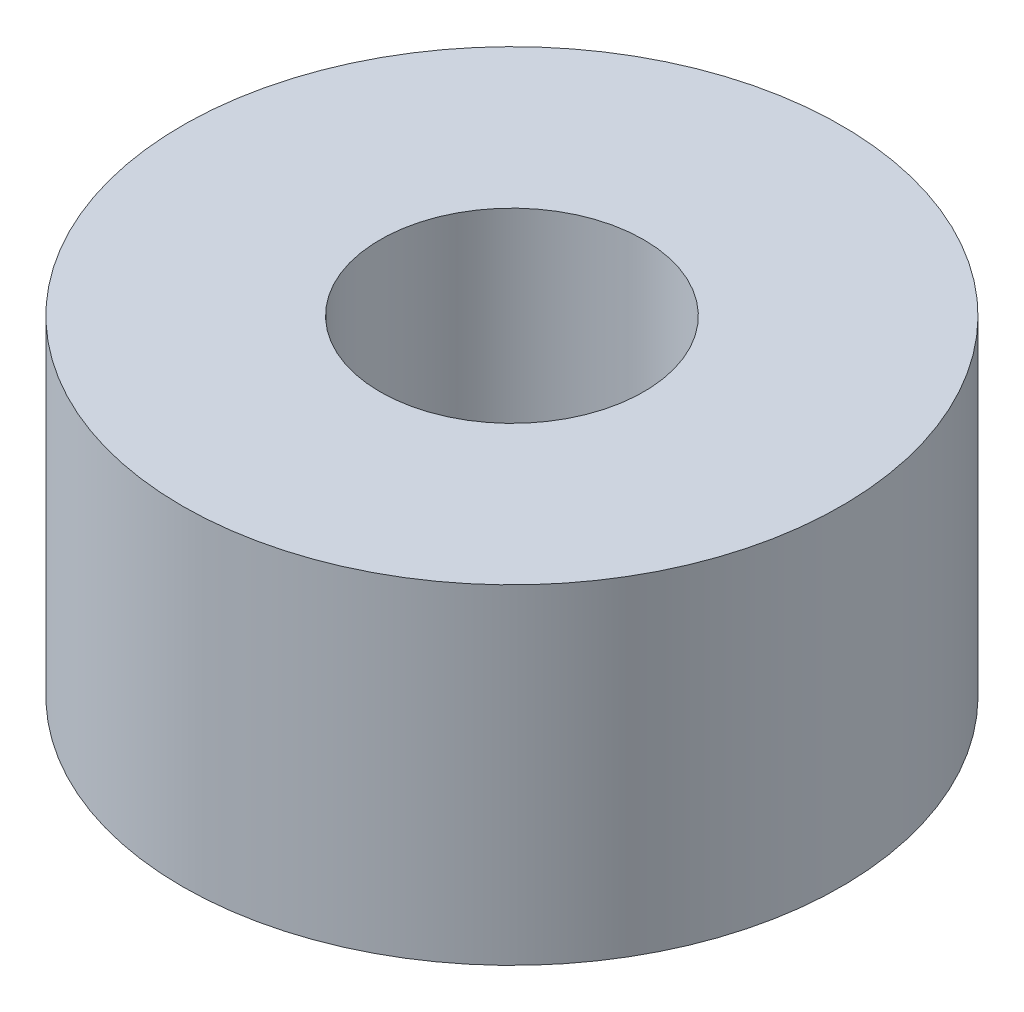
from build123d import *

# Parameters (mm, degrees)
SKETCH2_R           = 2.5
SKETCH2_R_2         = 1
BOSS_EXTRUDE1_DEPTH = 2.5


with BuildPart() as part:
    # Sketch2 → Boss-Extrude1 (new body)
    with BuildSketch(Plane(origin=(0, 0, 0), x_dir=(1, 0, 0), z_dir=(0, 1, 0))):
        Circle(SKETCH2_R)
        Circle(SKETCH2_R_2, mode=Mode.SUBTRACT)
    extrude(amount=BOSS_EXTRUDE1_DEPTH)


solid = part.part
